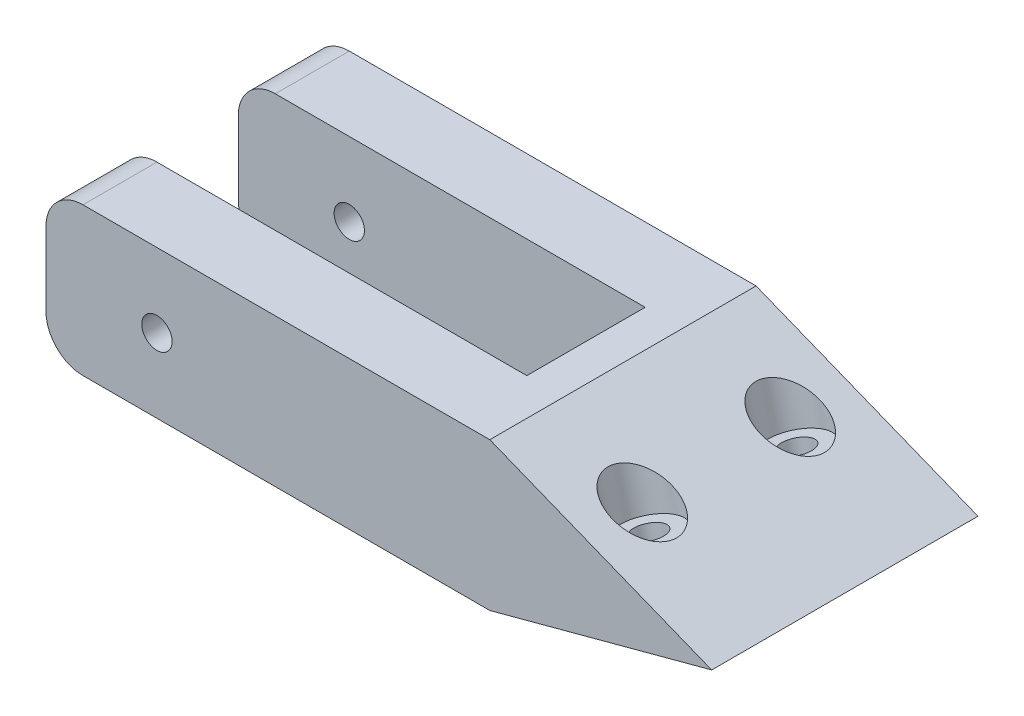
from build123d import *

# Parameters (mm, degrees)
BOSS_LARGEUR_DEPTH      = 10
BOSS_EXTRUDE4_DEPTH     = 8
CUT_VIS_REACH           = 78.573
SKETCH5_R               = 4
SKETCH5_4_R             = 4
SKETCH5_4_R_2           = 2.1
BOSS_VIS_DEPTH          = 8
CUT_EXTRUDE7_DEPTH      = 81.006249756
CUT_EXTRUDE7_DEPTH_BACK = 5
SKETCH4_6_R             = 2.05


with BuildPart() as part:
    # Sketch4 → Boss-Largeur (new body)
    with BuildSketch(Plane.XY):
        with BuildLine():
            ThreePointArc((-10, 10), (-13.535533906, 8.535533906), (-15, 5))
            Line((-15, 5), (-15, -5))
            ThreePointArc((-15, -5), (-13.535533906, -8.535533906), (-10, -10))
            Line((-10, -10), (45, -10))
            Line((45, -10), (75, -1.961524227))
            Line((75, -1.961524227), (45, 10))
            Line((45, 10), (-10, 10))
        make_face()
    extrude(amount=-BOSS_LARGEUR_DEPTH)

    # Sketch4_4 → Boss-Extrude4 (add)
    with BuildSketch(Plane.XY):
        Polygon((45, 10), (40, 10), (40, -10), (45, -10), (75, -1.961524227), align=None)
    extrude(amount=BOSS_EXTRUDE4_DEPTH)

    # Sketch5 → Cut-Vis (cut, up to next)
    with BuildSketch(Plane(origin=(5.514428415, -20.580127019, 0), x_dir=(0.9659258262890681, 0.25881904510252146, 0), z_dir=(0.25881904510252146, -0.9659258262890681, 0)), mode=Mode.PRIVATE) as cut_vis_sk1:
        with Locations((56.936757144, -2)):
            Circle(SKETCH5_R)
    cut_vis_tool1 = extrude(cut_vis_sk1.sketch, amount=-CUT_VIS_REACH, mode=Mode.PRIVATE) & part.part
    add(cut_vis_tool1.solids().sort_by_distance((60.511113, -5.84381, -2))[0], mode=Mode.SUBTRACT)

    # Sketch5_4 → Boss-Vis (add)
    with BuildSketch(Plane(origin=(5.514428415, -20.580127019, 0), x_dir=(0.9659258262890681, 0.25881904510252146, 0), z_dir=(0.25881904510252146, -0.9659258262890681, 0))):
        with Locations((56.936757144, -2)):
            Circle(SKETCH5_4_R)
        with Locations((56.936757144, -2)):
            Circle(SKETCH5_4_R_2, mode=Mode.SUBTRACT)
    extrude(amount=-BOSS_VIS_DEPTH)

    # Mirror4: part across plane


with BuildPart() as part_1:
    add(part.part)
    add(part.part.mirror(Plane.XY.offset(8)))

    # Sketch4_6 → Cut-Extrude7 (cut, two sides: drawn at the far end of the back side and taken through both)
    with BuildSketch(Plane.XY.offset(-CUT_EXTRUDE7_DEPTH_BACK)):
        Circle(SKETCH4_6_R)
    extrude(amount=CUT_EXTRUDE7_DEPTH + CUT_EXTRUDE7_DEPTH_BACK, mode=Mode.SUBTRACT)


solid = part_1.part
